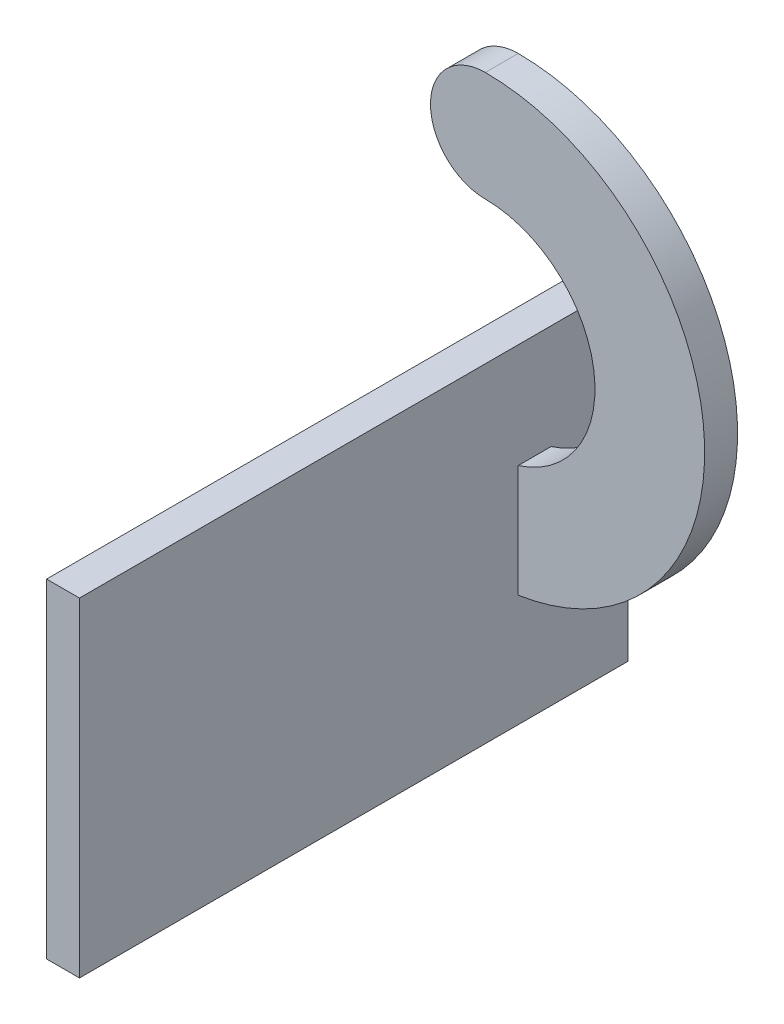
from build123d import *

# Parameters (mm, degrees)
BOSS_EXTRUDE1_DEPTH = 3
SKETCH2_W           = 3
SKETCH2_H           = 10
BOSS_EXTRUDE2_DEPTH = 3
SKETCH3_W           = 3
SKETCH3_H           = 3
BOSS_EXTRUDE3_DEPTH = 20
SKETCH4_W           = 3
SKETCH4_H           = 3
BOSS_EXTRUDE4_DEPTH = 10
SKETCH5_W           = 3
SKETCH5_H           = 30
BOSS_EXTRUDE5_DEPTH = 40
SKETCH6_W           = 3
SKETCH6_H           = 30
BOSS_EXTRUDE6_DEPTH = 7


with BuildPart() as part:
    # Sketch1 → Boss-Extrude1 (new body)
    with BuildSketch(Plane.XY):
        with BuildLine():
            ThreePointArc((0, 20), (-5, 15), (0, 10))
            ThreePointArc((0, 10), (10, 0), (0, -10))
            Line((0, -10), (0, -20))
            ThreePointArc((0, -20), (20, 0), (0, 20))
        make_face()
    extrude(amount=BOSS_EXTRUDE1_DEPTH)

    # Sketch2 → Boss-Extrude2 (add)
    with BuildSketch(Plane.ZY):
        with Locations((1.5, -15)):
            Rectangle(SKETCH2_W, SKETCH2_H)
    extrude(amount=-BOSS_EXTRUDE2_DEPTH)

    # Sketch3 → Boss-Extrude3 (add)
    with BuildSketch(Plane(origin=(0, -20, 0), x_dir=(-1, 0, 0), z_dir=(0, -1, 0))):
        with Locations((-1.5, -1.5)):
            Rectangle(SKETCH3_W, SKETCH3_H)
    extrude(amount=-BOSS_EXTRUDE3_DEPTH)

    # Sketch4 → Boss-Extrude4 (add)
    with BuildSketch(Plane.XZ.offset(20)):
        with Locations((1.5, 1.5)):
            Rectangle(SKETCH4_W, SKETCH4_H)
    extrude(amount=BOSS_EXTRUDE4_DEPTH)

    # Sketch5 → Boss-Extrude5 (add)
    with BuildSketch(Plane.XY.offset(3)):
        with Locations((1.5, -15)):
            Rectangle(SKETCH5_W, SKETCH5_H)
    extrude(amount=BOSS_EXTRUDE5_DEPTH)

    # Sketch6 → Boss-Extrude6 (add)
    with BuildSketch(Plane(origin=(0, 0, 0), x_dir=(-1, 0, 0), z_dir=(0, 0, -1))):
        with Locations((-1.5, -15)):
            Rectangle(SKETCH6_W, SKETCH6_H)
    extrude(amount=BOSS_EXTRUDE6_DEPTH)


solid = part.part
